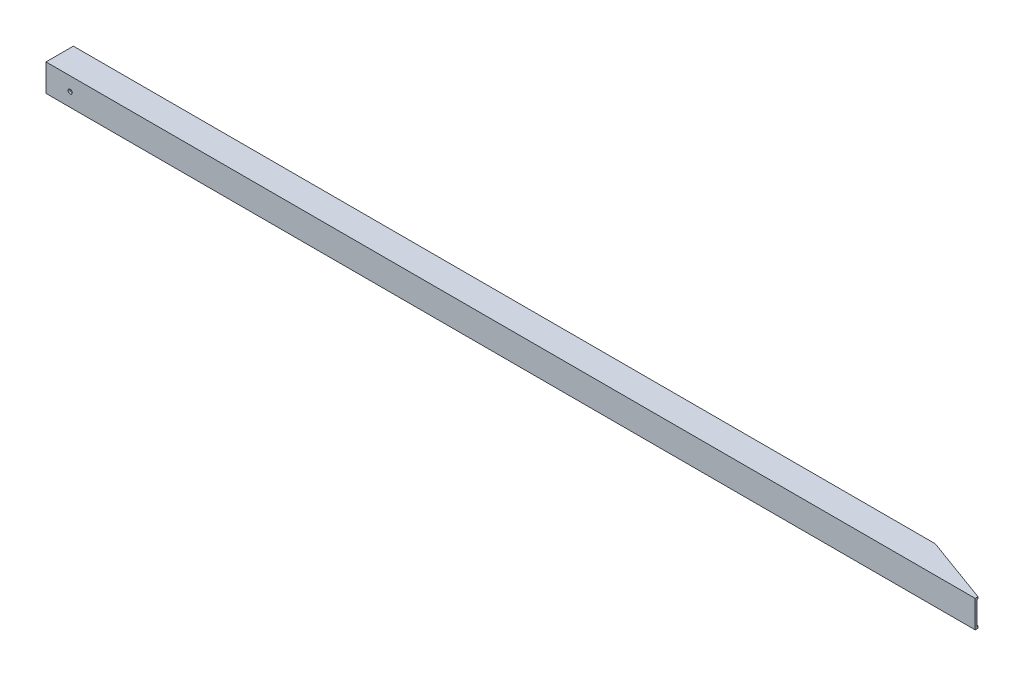
from build123d import *

# Parameters (mm, degrees)
SKETCH1_W               = 44.45
SKETCH1_H               = 44.45
SKETCH1_W_2             = 38.1
SKETCH1_H_2             = 38.1
BOSS_EXTRUDE1_DEPTH     = 1524
CUT_EXTRUDE1_DEPTH      = 45.45
F_1_4_CLEARANCE_HOLE1_D = 6.7564
CUT_EXTRUDE2_DEPTH      = 45.45


with BuildPart() as part:
    # Sketch1 → Boss-Extrude1 (new body)
    with BuildSketch(Plane(origin=(0, 0, 0), x_dir=(0, 0, -1), z_dir=(1, 0, 0))):
        with Locations((22.225, 22.225)):
            Rectangle(SKETCH1_W, SKETCH1_H)
        with Locations((22.225, 22.225)):
            Rectangle(SKETCH1_W_2, SKETCH1_H_2, mode=Mode.SUBTRACT)
    extrude(amount=BOSS_EXTRUDE1_DEPTH)

    # Sketch2 → Cut-Extrude1 (cut, through all)
    with BuildSketch(Plane(origin=(0, 44.45, 0), x_dir=(1, 0, 0), z_dir=(0, 1, 0))):
        Polygon((1524, 0), (1401.874628705, 44.45), (1524, 44.45), align=None)
    extrude(amount=-CUT_EXTRUDE1_DEPTH, mode=Mode.SUBTRACT)

    # 1/4 Clearance Hole1 (through all)
    with Locations(Plane.XY):
        with Locations((39.37, 22.225)):
            Hole(F_1_4_CLEARANCE_HOLE1_D / 2)

    # Sketch5 → Cut-Extrude2 (cut, through all)
    with BuildSketch(Plane(origin=(0, 44.45, 0), x_dir=(1, 0, 0), z_dir=(0, 1, 0))):
        Polygon((1524, 0), (1511.3, 0), (1511.3, 4.622421975), align=None)
    extrude(amount=-CUT_EXTRUDE2_DEPTH, mode=Mode.SUBTRACT)


solid = part.part
